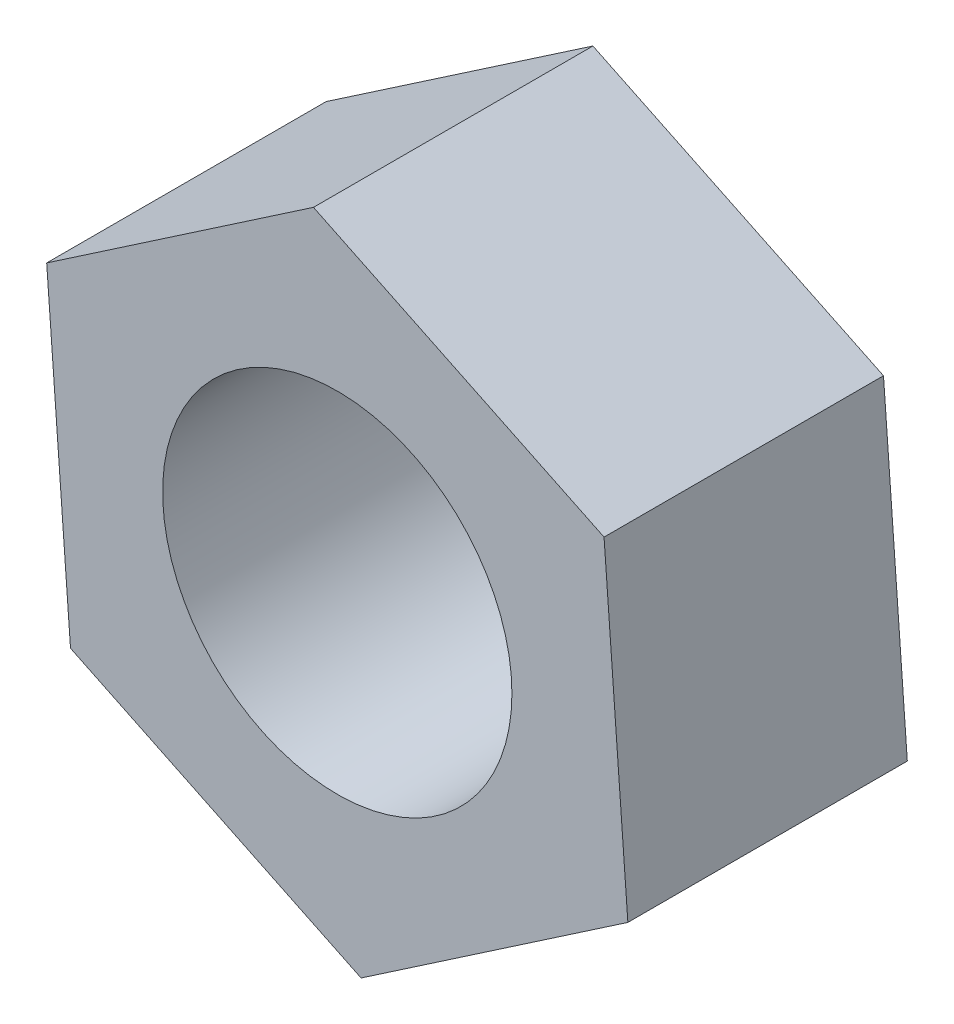
from build123d import *

# Parameters (mm, degrees)
SKETCH_1_R      = 2.5
EXTRUDE_1_DEPTH = 4


with BuildPart() as part:
    # ｽｹｯﾁ1 → ﾎﾞｽ - 押し出し1 (new body)
    with BuildSketch(Plane.XY):
        Polygon((-3.818608699, -2.598376596), (0.340955791, -4.606200439), (4.15956449, -2.007823843), (3.818608699, 2.598376596), (-0.340955791, 4.606200439), (-4.15956449, 2.007823843), align=None)
        Circle(SKETCH_1_R, mode=Mode.SUBTRACT)
    extrude(amount=EXTRUDE_1_DEPTH)


solid = part.part
